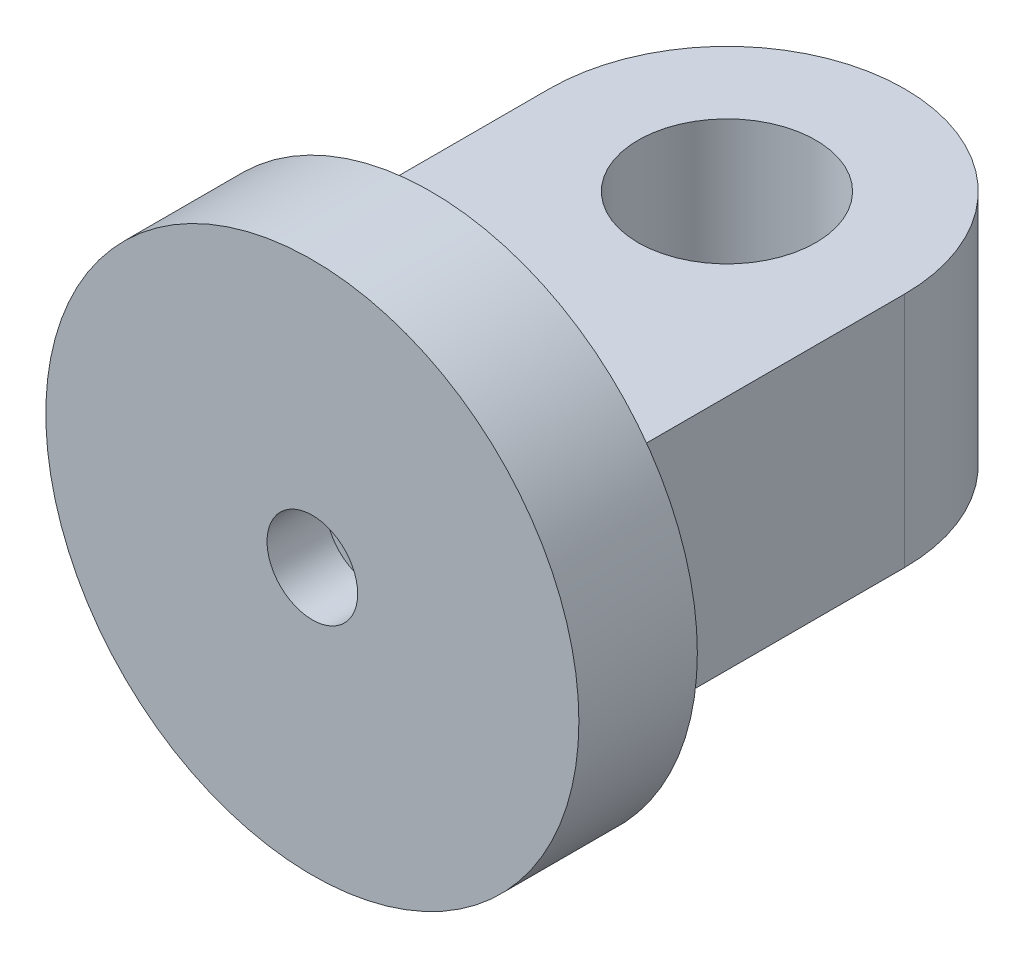
from build123d import *

# Parameters (mm, degrees)
SKETCH_1_R          = 15
EXTRUDE_1_DEPTH     = 20
SKETCH_2_R          = 45
EXTRUDE_2_DEPTH     = 20
SKETCH_3_R          = 7.65
CUT_EXTRUDE_1_DEPTH = 10


with BuildPart() as part:
    # 草图1 → 凸台-拉伸1 (new body, symmetric)
    with BuildSketch(Plane(origin=(0, 0, 0), x_dir=(1, 0, 0), z_dir=(0, 1, 0))):
        with BuildLine():
            Line((-30, 0), (-30, 50))
            ThreePointArc((-30, 50), (0, 80), (30, 50))
            Line((30, 50), (30, 0))
            Line((30, 0), (-30, 0))
        make_face()
        with Locations((0, 50)):
            Circle(SKETCH_1_R, mode=Mode.SUBTRACT)
    extrude(amount=EXTRUDE_1_DEPTH, both=True)

    # 草图2 → 凸台-拉伸2 (add)
    with BuildSketch(Plane.XY):
        Circle(SKETCH_2_R)
    extrude(amount=EXTRUDE_2_DEPTH)

    # 草图3 → 切除-拉伸1 (cut)
    with BuildSketch(Plane.XY.offset(20)):
        Circle(SKETCH_3_R)
    extrude(amount=-CUT_EXTRUDE_1_DEPTH, mode=Mode.SUBTRACT)


solid = part.part
